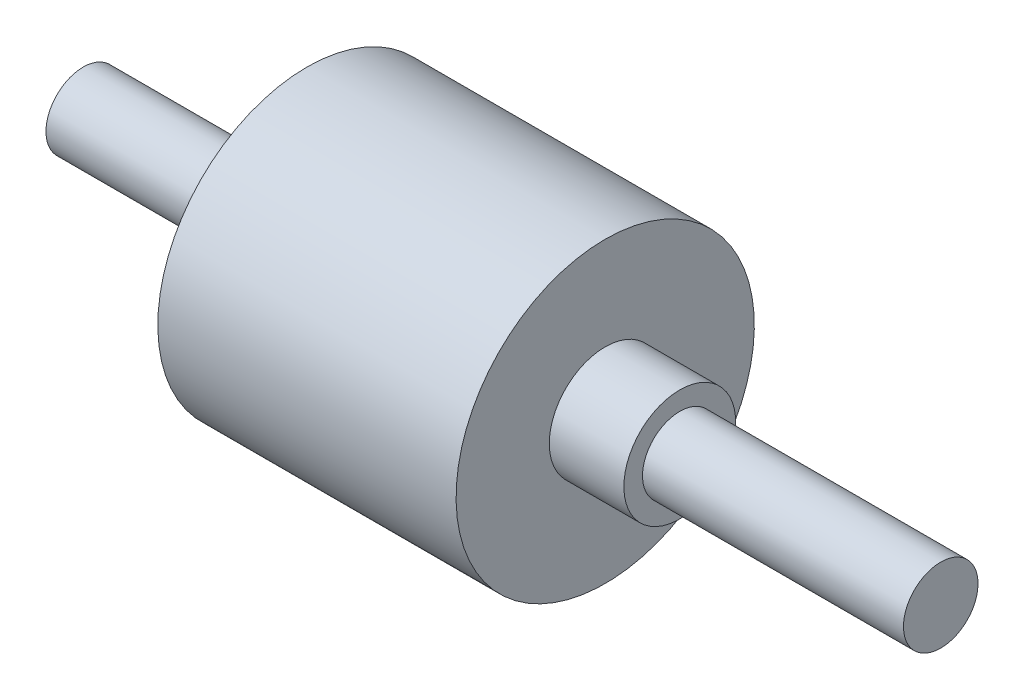
from build123d import *


with BuildPart() as part:
    # Sketch1 → Revolve2 (revolve)
    with BuildSketch(Plane.XY):
        Polygon((57.5, 0), (-57.5, 0), (-57.5, 5), (-27.5, 5), (-27.5, 20), (12.5, 20), (12.5, 7.5), (22.5, 7.5), (22.5, 5), (57.5, 5), align=None)
    revolve(axis=Axis((57.5, 0, 0), (-1, 0, 0)))


solid = part.part
